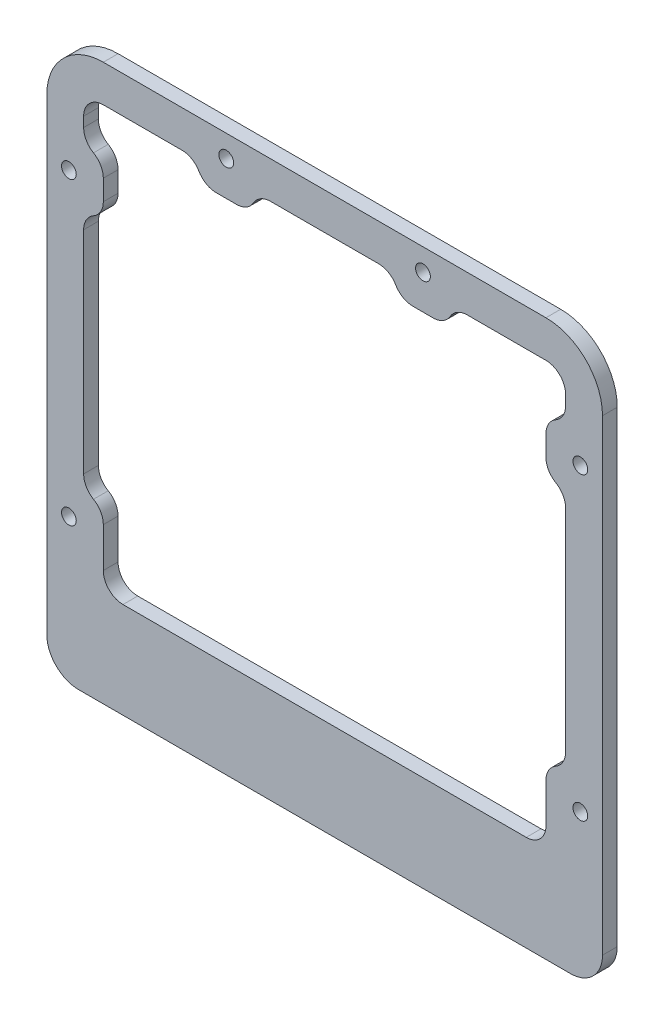
from build123d import *

# Parameters (mm, degrees)
SKETCH2_R           = 1.5
BOSS_EXTRUDE4_DEPTH = 3


with BuildPart() as part:
    # Sketch2 → Boss-Extrude4 (new body)
    with BuildSketch(Plane.XY.offset(-649.589603716)):
        with BuildLine():
            Line((40.97386422, 223.853671966), (-49.02613578, 223.853671966))
            ThreePointArc((-49.02613578, 223.853671966), (-57.157863764, 220.48539995), (-60.52613578, 212.353671966))
            Line((-60.52613578, 212.353671966), (-60.52613578, 117.353671966))
            ThreePointArc((-60.52613578, 117.353671966), (-58.622329858, 112.757477888), (-54.02613578, 110.853671966))
            Line((-54.02613578, 110.853671966), (45.97386422, 110.853671966))
            ThreePointArc((45.97386422, 110.853671966), (50.570058297, 112.757477888), (52.47386422, 117.353671966))
            Line((52.47386422, 117.353671966), (52.47386422, 212.353671966))
            ThreePointArc((52.47386422, 212.353671966), (49.105592203, 220.48539995), (40.97386422, 223.853671966))
        make_face()
        with Locations((-56.02613578, 201.353671966)):
            Circle(SKETCH2_R, mode=Mode.SUBTRACT)
        with Locations((-24.02613578, 219.356652382)):
            Circle(SKETCH2_R, mode=Mode.SUBTRACT)
        with Locations((15.97386422, 219.356652382)):
            Circle(SKETCH2_R, mode=Mode.SUBTRACT)
        with Locations((47.97386422, 201.353671966)):
            Circle(SKETCH2_R, mode=Mode.SUBTRACT)
        with Locations((47.97386422, 140.353671966)):
            Circle(SKETCH2_R, mode=Mode.SUBTRACT)
        with Locations((-56.02613578, 140.353671966)):
            Circle(SKETCH2_R, mode=Mode.SUBTRACT)
        with BuildLine():
            Line((-53.02613578, 192.353671966), (-53.02613578, 162.353671966))
            Line((-53.02613578, 162.353671966), (-53.02613578, 149.353671966))
            ThreePointArc((-53.02613578, 149.353671966), (-52.490237396, 147.353671966), (-51.02613578, 145.889570351))
            ThreePointArc((-51.02613578, 145.889570351), (-49.562034165, 144.425468736), (-49.02613578, 142.425468736))
            Line((-49.02613578, 142.425468736), (-49.02613578, 134.353671966))
            ThreePointArc((-49.02613578, 134.353671966), (-47.854562905, 131.525244841), (-45.02613578, 130.353671966))
            Line((-45.02613578, 130.353671966), (36.97386422, 130.353671966))
            ThreePointArc((36.97386422, 130.353671966), (39.802291344, 131.525244841), (40.97386422, 134.353671966))
            Line((40.97386422, 134.353671966), (40.97386422, 142.425468736))
            ThreePointArc((40.97386422, 142.425468736), (41.509762604, 144.425468736), (42.97386422, 145.889570351))
            ThreePointArc((42.97386422, 145.889570351), (44.437965835, 147.353671966), (44.97386422, 149.353671966))
            Line((44.97386422, 149.353671966), (44.97386422, 192.353671966))
            ThreePointArc((44.97386422, 192.353671966), (44.437965835, 194.353671966), (42.97386422, 195.817773581))
            ThreePointArc((42.97386422, 195.817773581), (41.509762604, 197.281875196), (40.97386422, 199.281875196))
            Line((40.97386422, 199.281875196), (40.97386422, 203.425468736))
            ThreePointArc((40.97386422, 203.425468736), (41.509762604, 205.425468736), (42.97386422, 206.889570351))
            ThreePointArc((42.97386422, 206.889570351), (44.437965835, 208.353671966), (44.97386422, 210.353671966))
            Line((44.97386422, 210.353671966), (44.97386422, 212.353671966))
            ThreePointArc((44.97386422, 212.353671966), (43.802291344, 215.182099091), (40.97386422, 216.353671966))
            Line((40.97386422, 216.353671966), (24.97386422, 216.353671966))
            ThreePointArc((24.97386422, 216.353671966), (22.97386422, 215.817773581), (21.509762604, 214.353671966))
            ThreePointArc((21.509762604, 214.353671966), (20.045660989, 212.889570351), (18.045660989, 212.353671966))
            Line((18.045660989, 212.353671966), (13.90206745, 212.353671966))
            ThreePointArc((13.90206745, 212.353671966), (11.90206745, 212.889570351), (10.437965835, 214.353671966))
            ThreePointArc((10.437965835, 214.353671966), (8.97386422, 215.817773581), (6.97386422, 216.353671966))
            Line((6.97386422, 216.353671966), (-15.02613578, 216.353671966))
            ThreePointArc((-15.02613578, 216.353671966), (-17.02613578, 215.817773581), (-18.490237396, 214.353671966))
            ThreePointArc((-18.490237396, 214.353671966), (-19.954339011, 212.889570351), (-21.954339011, 212.353671966))
            Line((-21.954339011, 212.353671966), (-26.09793255, 212.353671966))
            ThreePointArc((-26.09793255, 212.353671966), (-28.09793255, 212.889570351), (-29.562034165, 214.353671966))
            ThreePointArc((-29.562034165, 214.353671966), (-31.02613578, 215.817773581), (-33.02613578, 216.353671966))
            Line((-33.02613578, 216.353671966), (-49.02613578, 216.353671966))
            ThreePointArc((-49.02613578, 216.353671966), (-51.854562905, 215.182099091), (-53.02613578, 212.353671966))
            Line((-53.02613578, 212.353671966), (-53.02613578, 210.353671966))
            ThreePointArc((-53.02613578, 210.353671966), (-52.490237396, 208.353671966), (-51.02613578, 206.889570351))
            ThreePointArc((-51.02613578, 206.889570351), (-49.562034165, 205.425468736), (-49.02613578, 203.425468736))
            Line((-49.02613578, 203.425468736), (-49.02613578, 199.281875196))
            ThreePointArc((-49.02613578, 199.281875196), (-49.562034165, 197.281875196), (-51.02613578, 195.817773581))
            ThreePointArc((-51.02613578, 195.817773581), (-52.490237396, 194.353671966), (-53.02613578, 192.353671966))
        make_face(mode=Mode.SUBTRACT)
    extrude(amount=BOSS_EXTRUDE4_DEPTH)


solid = part.part
